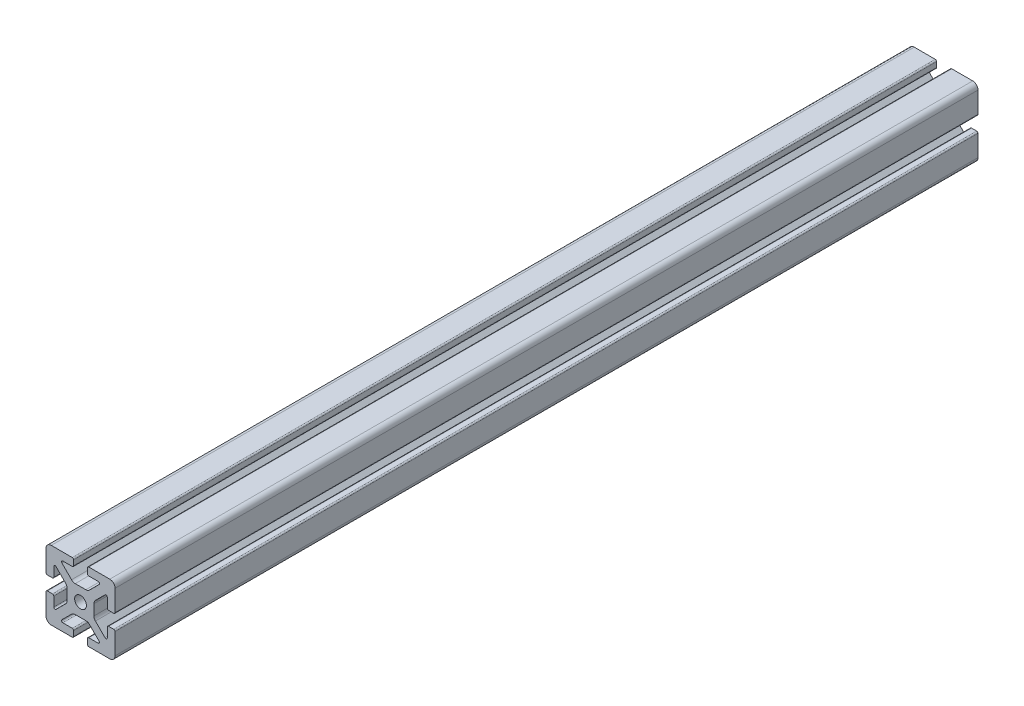
from build123d import *

# Parameters (mm, degrees)
SKETCH1_R           = 3.4036
BOSS_EXTRUDE1_DEPTH = 250


with BuildPart() as part:
    # Sketch1 → Boss-Extrude1 (new body, symmetric)
    with BuildSketch(Plane.XY):
        with BuildLine():
            Line((-20, 16.952), (-20, 4.7625))
            ThreePointArc((-20, 4.7625), (-19.776815367, 4.223684633), (-19.238, 4.0005))
            Line((-19.238, 4.0005), (-16.2662, 4.0005))
            ThreePointArc((-16.2662, 4.0005), (-15.727384633, 4.223684633), (-15.5042, 4.7625))
            Line((-15.5042, 4.7625), (-15.5042, 10.2235))
            ThreePointArc((-15.5042, 10.2235), (-15.033804775, 10.927496204), (-14.203384633, 10.762315367))
            Line((-14.203384633, 10.762315367), (-8.635059555, 5.19399029))
            ThreePointArc((-8.635059555, 5.19399029), (-7.985348265, 4.221628629), (-7.7572, 3.074649845))
            Line((-7.7572, 3.074649845), (-7.7572, -3.074649845))
            ThreePointArc((-7.7572, -3.074649845), (-7.985348265, -4.221628629), (-8.635059555, -5.19399029))
            Line((-8.635059555, -5.19399029), (-14.203384633, -10.762315367))
            ThreePointArc((-14.203384633, -10.762315367), (-15.033804775, -10.927496204), (-15.5042, -10.2235))
            Line((-15.5042, -10.2235), (-15.5042, -4.7625))
            ThreePointArc((-15.5042, -4.7625), (-15.727384633, -4.223684633), (-16.2662, -4.0005))
            Line((-16.2662, -4.0005), (-19.238, -4.0005))
            ThreePointArc((-19.238, -4.0005), (-19.776815367, -4.223684633), (-20, -4.7625))
            Line((-20, -4.7625), (-20, -16.952))
            ThreePointArc((-20, -16.952), (-19.107261469, -19.107261469), (-16.952, -20))
            Line((-16.952, -20), (-4.7625, -20))
            ThreePointArc((-4.7625, -20), (-4.223684633, -19.776815367), (-4.0005, -19.238))
            Line((-4.0005, -19.238), (-4.0005, -16.2662))
            ThreePointArc((-4.0005, -16.2662), (-4.223684633, -15.727384633), (-4.7625, -15.5042))
            Line((-4.7625, -15.5042), (-10.2235, -15.5042))
            ThreePointArc((-10.2235, -15.5042), (-10.927496204, -15.033804775), (-10.762315367, -14.203384633))
            Line((-10.762315367, -14.203384633), (-5.19399029, -8.635059555))
            ThreePointArc((-5.19399029, -8.635059555), (-4.221628629, -7.985348265), (-3.074649845, -7.7572))
            Line((-3.074649845, -7.7572), (3.074649845, -7.7572))
            ThreePointArc((3.074649845, -7.7572), (4.221628629, -7.985348265), (5.19399029, -8.635059555))
            Line((5.19399029, -8.635059555), (10.762315367, -14.203384633))
            ThreePointArc((10.762315367, -14.203384633), (10.927496204, -15.033804775), (10.2235, -15.5042))
            Line((10.2235, -15.5042), (4.7625, -15.5042))
            ThreePointArc((4.7625, -15.5042), (4.223684633, -15.727384633), (4.0005, -16.2662))
            Line((4.0005, -16.2662), (4.0005, -19.238))
            ThreePointArc((4.0005, -19.238), (4.223684633, -19.776815367), (4.7625, -20))
            Line((4.7625, -20), (16.952, -20))
            ThreePointArc((16.952, -20), (19.107261469, -19.107261469), (20, -16.952))
            Line((20, -16.952), (20, -4.7625))
            ThreePointArc((20, -4.7625), (19.776815367, -4.223684633), (19.238, -4.0005))
            Line((19.238, -4.0005), (16.2662, -4.0005))
            ThreePointArc((16.2662, -4.0005), (15.727384633, -4.223684633), (15.5042, -4.7625))
            Line((15.5042, -4.7625), (15.5042, -10.2235))
            ThreePointArc((15.5042, -10.2235), (15.033804775, -10.927496204), (14.203384633, -10.762315367))
            Line((14.203384633, -10.762315367), (8.635059555, -5.19399029))
            ThreePointArc((8.635059555, -5.19399029), (7.985348265, -4.221628629), (7.7572, -3.074649845))
            Line((7.7572, -3.074649845), (7.7572, 3.074649845))
            ThreePointArc((7.7572, 3.074649845), (7.985348265, 4.221628629), (8.635059555, 5.19399029))
            Line((8.635059555, 5.19399029), (14.203384633, 10.762315367))
            ThreePointArc((14.203384633, 10.762315367), (15.033804775, 10.927496204), (15.5042, 10.2235))
            Line((15.5042, 10.2235), (15.5042, 4.7625))
            ThreePointArc((15.5042, 4.7625), (15.727384633, 4.223684633), (16.2662, 4.0005))
            Line((16.2662, 4.0005), (19.238, 4.0005))
            ThreePointArc((19.238, 4.0005), (19.776815367, 4.223684633), (20, 4.7625))
            Line((20, 4.7625), (20, 16.952))
            ThreePointArc((20, 16.952), (19.107261469, 19.107261469), (16.952, 20))
            Line((16.952, 20), (4.7625, 20))
            ThreePointArc((4.7625, 20), (4.223684633, 19.776815367), (4.0005, 19.238))
            Line((4.0005, 19.238), (4.0005, 16.2662))
            ThreePointArc((4.0005, 16.2662), (4.223684633, 15.727384633), (4.7625, 15.5042))
            Line((4.7625, 15.5042), (10.2235, 15.5042))
            ThreePointArc((10.2235, 15.5042), (10.927496204, 15.033804775), (10.762315367, 14.203384633))
            Line((10.762315367, 14.203384633), (5.19399029, 8.635059555))
            ThreePointArc((5.19399029, 8.635059555), (4.221628629, 7.985348265), (3.074649845, 7.7572))
            Line((3.074649845, 7.7572), (-3.074649845, 7.7572))
            ThreePointArc((-3.074649845, 7.7572), (-4.221628629, 7.985348265), (-5.19399029, 8.635059555))
            Line((-5.19399029, 8.635059555), (-10.762315367, 14.203384633))
            ThreePointArc((-10.762315367, 14.203384633), (-10.927496204, 15.033804775), (-10.2235, 15.5042))
            Line((-10.2235, 15.5042), (-4.7625, 15.5042))
            ThreePointArc((-4.7625, 15.5042), (-4.223684633, 15.727384633), (-4.0005, 16.2662))
            Line((-4.0005, 16.2662), (-4.0005, 19.238))
            ThreePointArc((-4.0005, 19.238), (-4.223684633, 19.776815367), (-4.7625, 20))
            Line((-4.7625, 20), (-16.952, 20))
            ThreePointArc((-16.952, 20), (-19.107261469, 19.107261469), (-20, 16.952))
        make_face()
        Circle(SKETCH1_R, mode=Mode.SUBTRACT)
    extrude(amount=BOSS_EXTRUDE1_DEPTH, both=True)


solid = part.part
